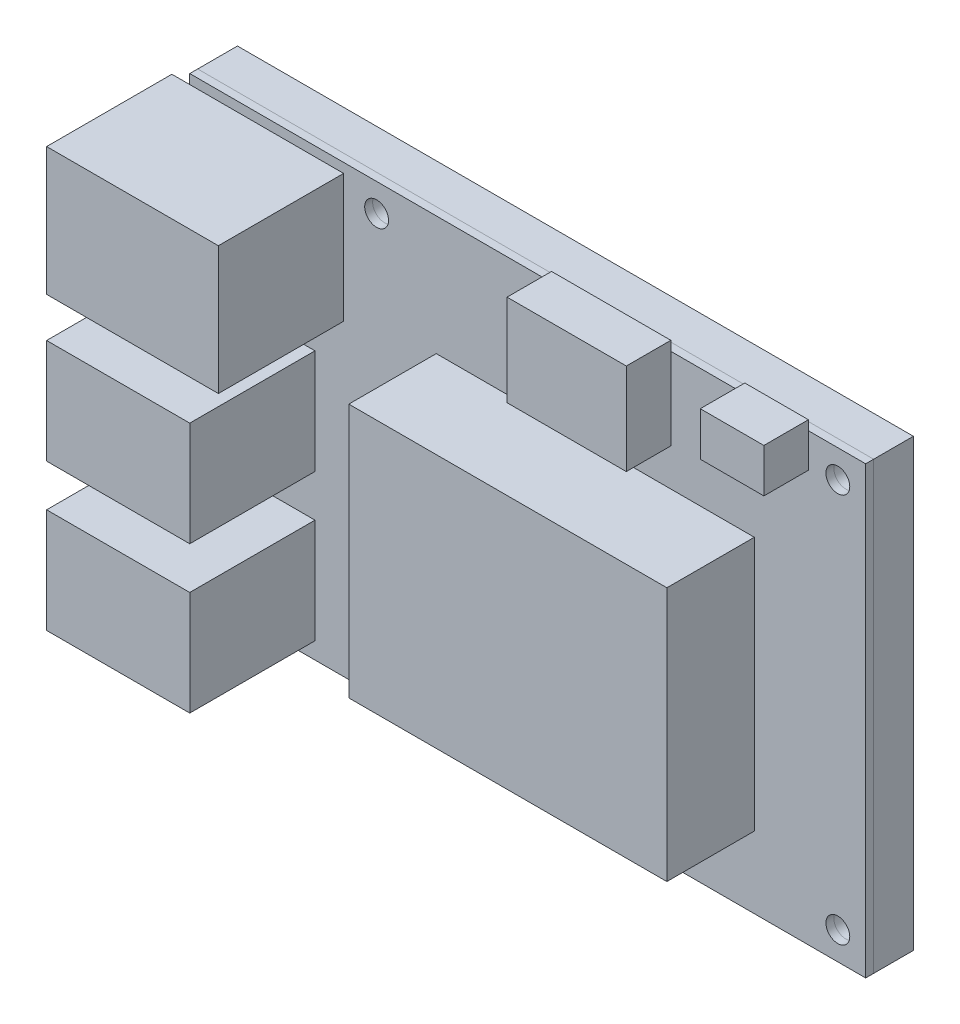
from build123d import *

# Parameters (mm, degrees)
SKETCH1_W           = 85
SKETCH1_H           = 56
SKETCH1_R           = 1.5
BOSS_EXTRUDE1_DEPTH = 1
SKETCH1_2_W         = 85
SKETCH1_2_H         = 56
SKETCH1_2_R         = 1.5
BOSS_EXTRUDE2_DEPTH = 5
SKETCH3_W           = 40
SKETCH3_H           = 32
BOSS_EXTRUDE3_DEPTH = 11
SKETCH4_W           = 18
SKETCH4_H           = 13.14
SKETCH4_W_2         = 21.6
SKETCH4_H_2         = 16.1
BOSS_EXTRUDE4_DEPTH = 15.75
SKETCH5_W           = 15
SKETCH5_H           = 11.5
SKETCH5_W_2         = 8
SKETCH5_H_2         = 5.5
BOSS_EXTRUDE5_DEPTH = 5.6


with BuildPart() as part:
    # Sketch1 → Boss-Extrude1 (new body)
    with BuildSketch(Plane.XY):
        with Locations((6.081574074, 9.647501164)):
            Rectangle(SKETCH1_W, SKETCH1_H)
        with Locations((-12.918426004, 34.147501164)):
            Circle(SKETCH1_R, mode=Mode.SUBTRACT)
        with Locations((-12.918426004, -14.852498836)):
            Circle(SKETCH1_R, mode=Mode.SUBTRACT)
        with Locations((45.081574074, 34.147501164)):
            Circle(SKETCH1_R, mode=Mode.SUBTRACT)
        with Locations((45.081574074, -14.852498836)):
            Circle(SKETCH1_R, mode=Mode.SUBTRACT)
    extrude(amount=BOSS_EXTRUDE1_DEPTH)

    # Sketch3 → Boss-Extrude3 (add)
    with BuildSketch(Plane.XY.offset(1)):
        with Locations((14.581574074, 6.647501164)):
            Rectangle(SKETCH3_W, SKETCH3_H)
    extrude(amount=BOSS_EXTRUDE3_DEPTH)

    # Sketch4 → Boss-Extrude4 (add)
    with BuildSketch(Plane.XY.offset(1)):
        with Locations((-29.667902016, 8.757501164)):
            Rectangle(SKETCH4_W, SKETCH4_H)
        with Locations((-29.667902016, -9.682498836)):
            Rectangle(SKETCH4_W, SKETCH4_H)
        with Locations((-27.867902016, 28.397501164)):
            Rectangle(SKETCH4_W_2, SKETCH4_H_2)
    extrude(amount=BOSS_EXTRUDE4_DEPTH)

    # Sketch5 → Boss-Extrude5 (add)
    with BuildSketch(Plane.XY.offset(1)):
        with Locations((16.581574074, 33.097501164)):
            Rectangle(SKETCH5_W, SKETCH5_H)
        with Locations((37.381574074, 36.097501164)):
            Rectangle(SKETCH5_W_2, SKETCH5_H_2)
    extrude(amount=BOSS_EXTRUDE5_DEPTH)


with BuildPart() as body_2:
    # Sketch1_2 → Boss-Extrude2 (new body)
    with BuildSketch(Plane.XY):
        with Locations((6.081574074, 9.647501164)):
            Rectangle(SKETCH1_2_W, SKETCH1_2_H)
        with Locations((-12.918426004, 34.147501164)):
            Circle(SKETCH1_2_R, mode=Mode.SUBTRACT)
        with Locations((-12.918426004, -14.852498836)):
            Circle(SKETCH1_2_R, mode=Mode.SUBTRACT)
        with Locations((45.081574074, 34.147501164)):
            Circle(SKETCH1_2_R, mode=Mode.SUBTRACT)
        with Locations((45.081574074, -14.852498836)):
            Circle(SKETCH1_2_R, mode=Mode.SUBTRACT)
    extrude(amount=-BOSS_EXTRUDE2_DEPTH)


solid = Compound([part.part, body_2.part])
